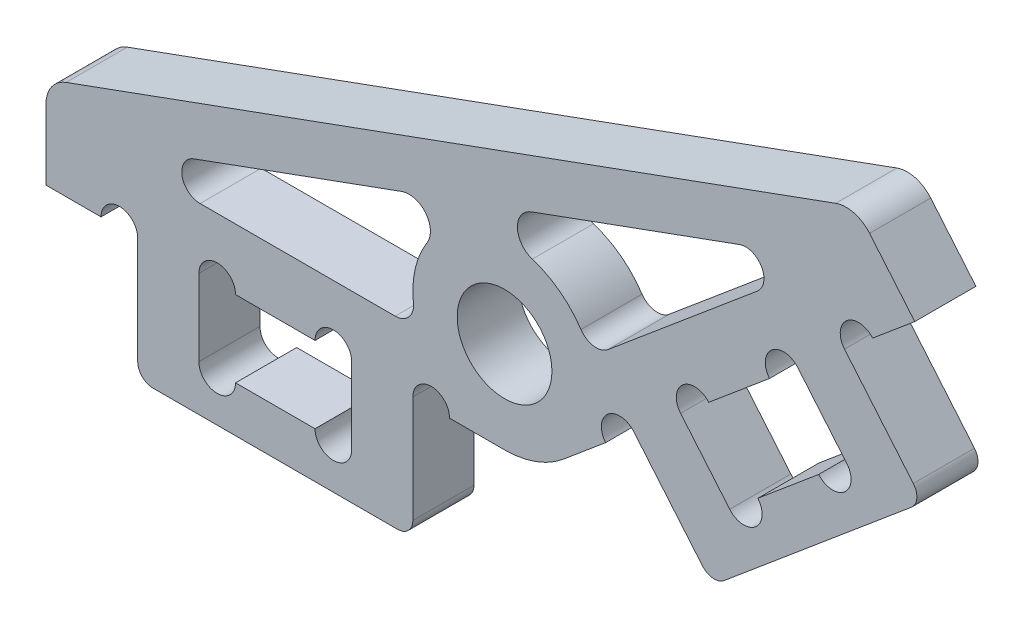
from build123d import *

# Parameters (mm, degrees)
SKETCH_1_R          = 1.55
EXTRUDE_1_DEPTH     = 1
FILLET_1_R          = 0.6
EXTRUDE_2_DEPTH     = 2
SKETCH_3_R          = 0.6
CUT_EXTRUDE_1_DEPTH = 3
FILLET_2_R          = 0.5
FILLET_3_R          = 1


with BuildPart() as part:
    # 草图1 → 凸台-拉伸1 (new body, symmetric)
    with BuildSketch(Plane.XY):
        with BuildLine():
            Line((0, -3), (-15, -3))
            Line((-15, -3), (-15, 0))
            Line((-15, 0), (11.490666647, 9.641814145))
            Line((11.490666647, 9.641814145), (13.419029476, 7.343680816))
            Line((13.419029476, 7.343680816), (1.928362829, -2.298133329))
            ThreePointArc((1.928362829, -2.298133329), (1.02606043, -2.819077862), (0, -3))
        make_face()
        Circle(SKETCH_1_R, mode=Mode.SUBTRACT)
        with BuildLine():
            Line((-13.361770819, -1), (-3.364453737, 2.63872584))
            ThreePointArc((-3.364453737, 2.63872584), (-2.579616657, 2.419704921), (-2.533815922, 1.606168383))
            ThreePointArc((-2.533815922, 1.606168383), (-2.981013424, 0.336985115), (-2.828427125, -1))
            Line((-2.828427125, -1), (-13.361770819, -1))
        make_face(mode=Mode.SUBTRACT)
        with BuildLine():
            Line((10.878497896, 7.822736283), (2.809488491, 1.052033468))
            ThreePointArc((2.809488491, 1.052033468), (2.066978912, 2.174304068), (0.908590471, 2.859101844))
            ThreePointArc((0.908590471, 2.859101844), (0.420744663, 3.511747133), (0.881180814, 4.184010443))
            Line((0.881180814, 4.184010443), (10.878497896, 7.822736283))
        make_face(mode=Mode.SUBTRACT)
    extrude(amount=EXTRUDE_1_DEPTH, both=True)

    # 圆角1
    fillet_1_edges = [part.edges().sort_by_distance(p)[0] for p in [
        (-13.361770819, -1, 0),
        (-2.828427125, -1, 0),
        (10.878497896, 7.822736283, 0),
        (2.809488491, 1.052033468, 0),
    ]]
    fillet(fillet_1_edges, radius=FILLET_1_R)

    # 草图2 → 凸台-拉伸2 (add)
    with BuildSketch(Plane.XY.offset(1)):
        Polygon((-12, -3), (-10, -3), (-10, -5.5), (-5, -5.5), (-5, -3), (-3, -3), (-3, -7), (-12, -7), align=None)
        Polygon((11.120896146, 5.415317987), (13.692046585, 2.351140214), (6.797646597, -3.433948273), (4.226496158, -0.3697705), (5.758585045, 0.915804719), (7.365554069, -0.999306389), (11.195776284, 2.21463166), (9.58880726, 4.129742768), align=None)
    extrude(amount=-EXTRUDE_2_DEPTH)

    # 草图3 → 切除-拉伸1 (cut, through all)
    with BuildSketch(Plane.XY.offset(1)):
        with Locations((-5.6, -3)):
            Circle(SKETCH_3_R)
        with Locations((-5.6, -5.5)):
            Circle(SKETCH_3_R)
        with Locations((-9.4, -3)):
            Circle(SKETCH_3_R)
        with Locations((-9.4, -5.5)):
            Circle(SKETCH_3_R)
        with Locations((6.218211711, 1.301477285)):
            Circle(SKETCH_3_R)
        with Locations((7.825180735, -0.613633823)):
            Circle(SKETCH_3_R)
        with Locations((9.129180594, 3.744070202)):
            Circle(SKETCH_3_R)
        with Locations((10.736149619, 1.828959094)):
            Circle(SKETCH_3_R)
        with Locations((-12.6, -3)):
            Circle(SKETCH_3_R)
        with Locations((-2.4, -3)):
            Circle(SKETCH_3_R)
        with Locations((3.766869493, -0.755443066)):
            Circle(SKETCH_3_R)
        with Locations((11.580522812, 5.800990553)):
            Circle(SKETCH_3_R)
    extrude(amount=-CUT_EXTRUDE_1_DEPTH, mode=Mode.SUBTRACT)

    # 圆角2
    fillet_2_edges = [part.edges().sort_by_distance(p)[0] for p in [
        (13.692046585, 2.351140214, 0),
        (6.797646597, -3.433948273, 0),
        (-12, -7, 0),
        (-3, -7, 0),
    ]]
    fillet(fillet_2_edges, radius=FILLET_2_R)

    # 圆角3
    fillet_3_edges = [part.edges().sort_by_distance(p)[0] for p in [
        (-15, 0, 0),
        (11.490666647, 9.641814145, 0),
    ]]
    fillet(fillet_3_edges, radius=FILLET_3_R)


solid = part.part
